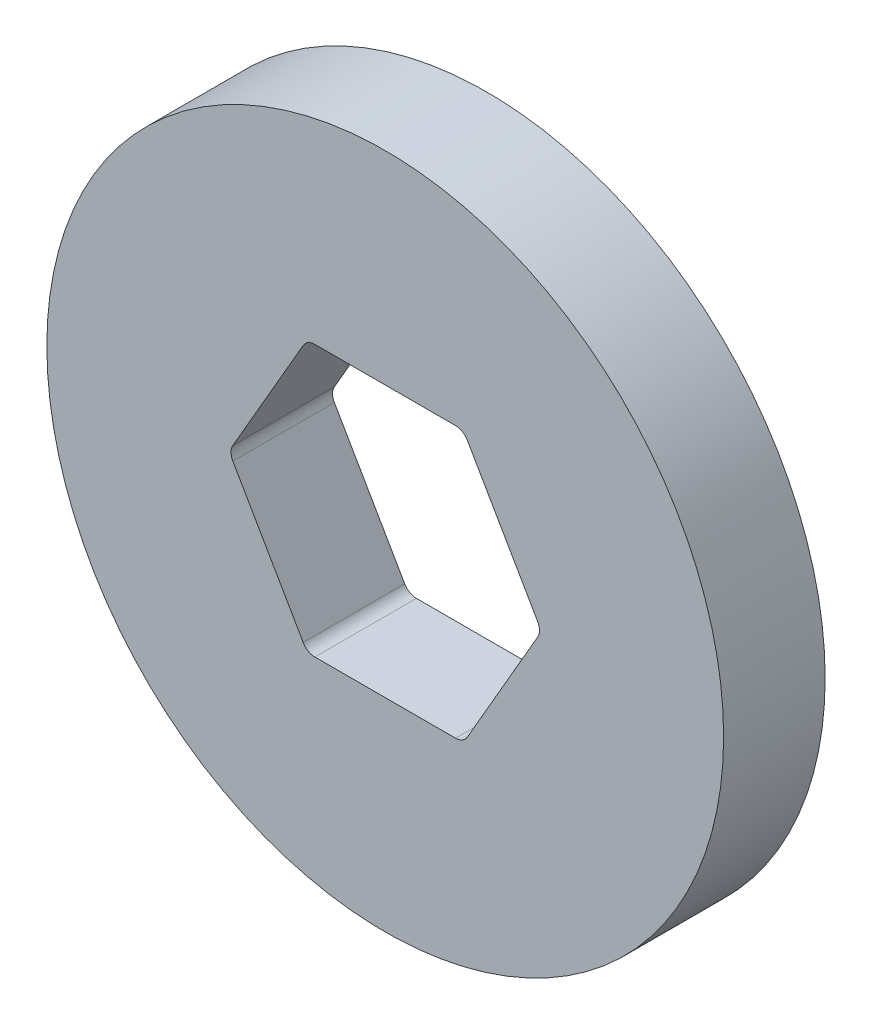
from build123d import *

# Parameters (mm, degrees)
SKETCH1_R           = 50
BOSS_EXTRUDE1_DEPTH = 7.5
FILLET1_R           = 2


with BuildPart() as part:
    # Sketch1 → Boss-Extrude1 (new body, symmetric)
    with BuildSketch(Plane.XY):
        Circle(SKETCH1_R)
        Polygon((23.094010768, 0), (11.547005384, 20), (-11.547005384, 20), (-23.094010768, 0), (-11.547005384, -20), (11.547005384, -20), align=None, mode=Mode.SUBTRACT)
    extrude(amount=BOSS_EXTRUDE1_DEPTH, both=True)

    # Fillet1
    fillet1_edges = [part.edges().sort_by_distance(p)[0] for p in [
        (23.094010768, 0, 0),
        (11.547005384, 20, 0),
        (-11.547005384, 20, 0),
        (-23.094010768, 0, 0),
        (-11.547005384, -20, 0),
        (11.547005384, -20, 0),
    ]]
    fillet(fillet1_edges, radius=FILLET1_R)


solid = part.part
